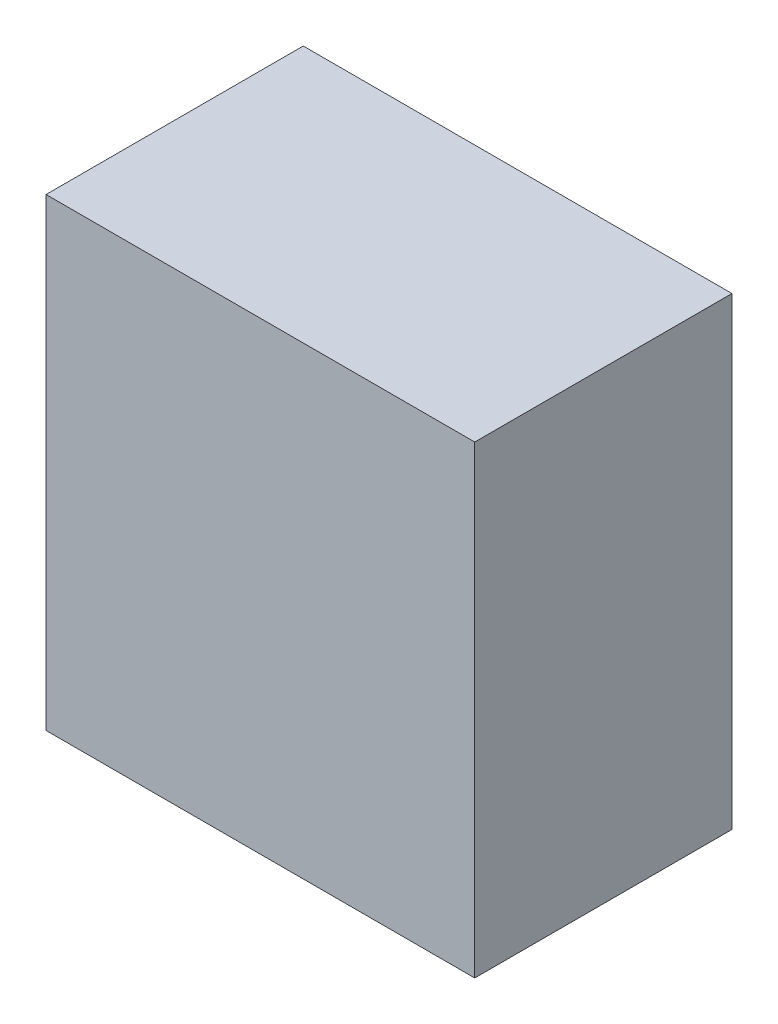
from build123d import *

# Parameters (mm, degrees)
SKETCH1_W           = 145
SKETCH1_H           = 157
BOSS_EXTRUDE1_DEPTH = 87


with BuildPart() as part:
    # Sketch1 → Boss-Extrude1 (new body)
    with BuildSketch(Plane.XY):
        with Locations((232.5, 22.77)):
            Rectangle(SKETCH1_W, SKETCH1_H)
    extrude(amount=BOSS_EXTRUDE1_DEPTH)


solid = part.part
